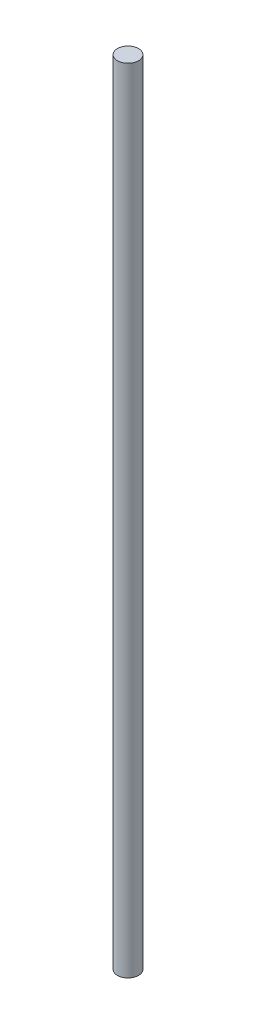
from build123d import *

# Parameters (mm, degrees)
SKETCH_1_R      = 4
EXTRUDE_1_DEPTH = 300


with BuildPart() as part:
    # 草图1 → 凸台-拉伸1 (new body)
    with BuildSketch(Plane(origin=(0, 0, 0), x_dir=(1, 0, 0), z_dir=(0, 1, 0))):
        Circle(SKETCH_1_R)
    extrude(amount=EXTRUDE_1_DEPTH)


solid = part.part
